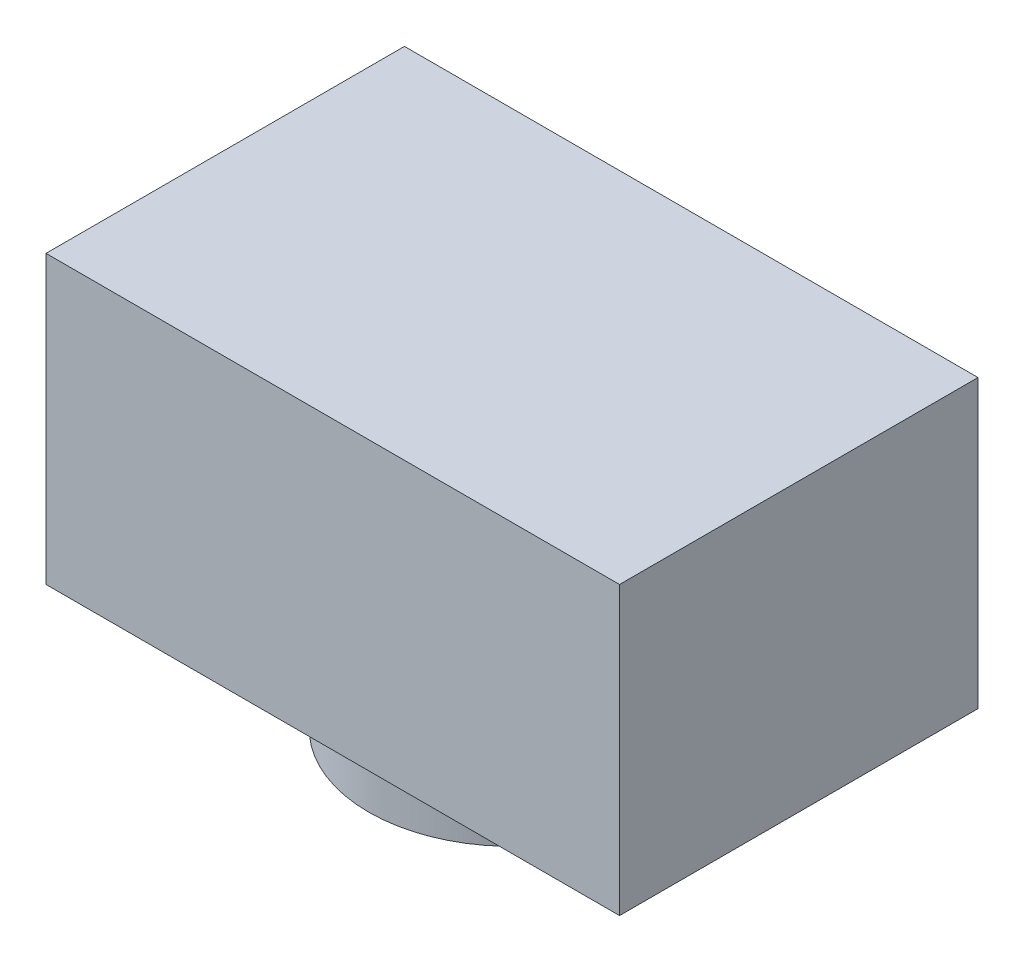
from build123d import *

# Parameters (mm, degrees)
SKETCH1_W           = 8
SKETCH1_H           = 4
BOSS_EXTRUDE1_DEPTH = 5
SKETCH2_R           = 2
BOSS_EXTRUDE2_DEPTH = 1
SKETCH5_R           = 1
CUT_EXTRUDE1_DEPTH  = 0.25


with BuildPart() as part:
    # Sketch1 → Boss-Extrude1 (new body)
    with BuildSketch(Plane.XY):
        Rectangle(SKETCH1_W, SKETCH1_H)
    extrude(amount=BOSS_EXTRUDE1_DEPTH)

    # Sketch2 → Boss-Extrude2 (add)
    with BuildSketch(Plane(origin=(0, -2, 0), x_dir=(-1, 0, 0), z_dir=(0, -1, 0))):
        with Locations((0, -2.5)):
            Circle(SKETCH2_R)
    extrude(amount=BOSS_EXTRUDE2_DEPTH)

    # Sketch5 → Cut-Extrude1 (cut)
    with BuildSketch(Plane(origin=(0, -3, 0), x_dir=(-1, 0, 0), z_dir=(0, -1, 0))):
        with Locations((0, -2.5)):
            Circle(SKETCH5_R)
    extrude(amount=-CUT_EXTRUDE1_DEPTH, mode=Mode.SUBTRACT)


solid = part.part
